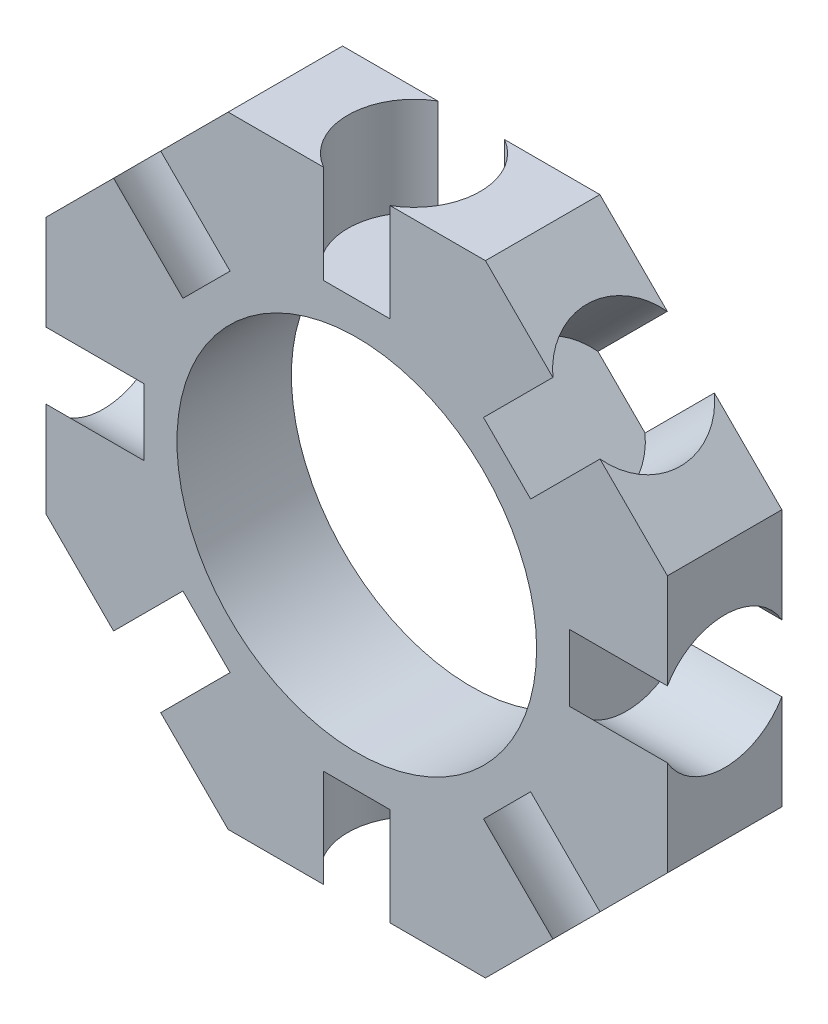
from build123d import *

# Parameters (mm, degrees)
SKETCH1_R           = 11
BOSS_EXTRUDE1_DEPTH = 3.5
SKETCH2_R           = 4.05
CUT_EXTRUDE3_DEPTH  = 6
CIRPATTERN1_COUNT   = 8


with BuildPart() as part:
    # Sketch1 → Boss-Extrude1 (new, symmetric)
    with BuildSketch(Plane.XY):
        Polygon((7.870057685, 19), (-7.870057685, 19), (-19, 7.870057685), (-19, -7.870057685), (-7.870057685, -19), (7.870057685, -19), (19, -7.870057685), (19, 7.870057685), align=None)
        Circle(SKETCH1_R, mode=Mode.SUBTRACT)
    extrude(amount=BOSS_EXTRUDE1_DEPTH, both=True)

    # Sketch2 → Cut-Extrude3 (cut)
    with BuildSketch(Plane(origin=(0, -19, 0), x_dir=(-1, 0, 0), z_dir=(0, -1, 0))):
        Circle(SKETCH2_R)
    cut_extrude3 = extrude(amount=-CUT_EXTRUDE3_DEPTH, mode=Mode.SUBTRACT)

    # CirPattern1: Cut-Extrude3 ×8 about axis
    cirpattern1_axis = Axis((0, 0, 3.5), (0, 0, 1))
    for i in range(1, CIRPATTERN1_COUNT):
        add(cut_extrude3.rotate(cirpattern1_axis, i * 360 / CIRPATTERN1_COUNT), mode=Mode.SUBTRACT)


solid = part.part
